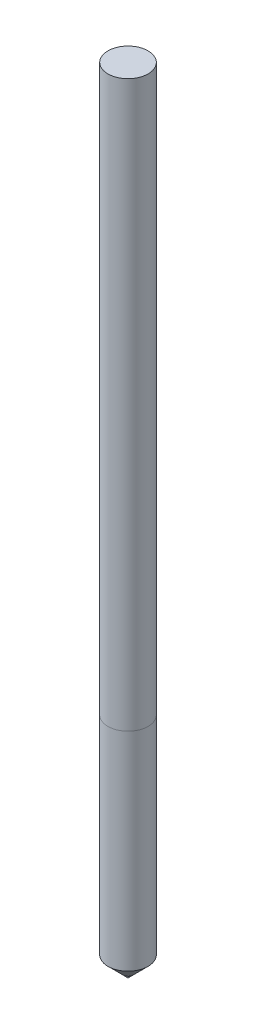
from build123d import *


with BuildPart() as part:
    # Sketch1 → Revolve1 (revolve)
    with BuildSketch(Plane.XY):
        Polygon((-2.083073871, 65.090995785), (-2.083073871, -69.909004215), (1.416926129, -69.909004215), (1.416926129, -33.613671522), (1.416926129, 65.090995785), align=None)
        Polygon((1.416926129, -69.909004215), (-2.083073871, -69.909004215), (1.416926129, -73.413671522), align=None)
    revolve(axis=Axis((1.416926129, -73.413671522, 0), (0, 1, 0)))


solid = part.part
